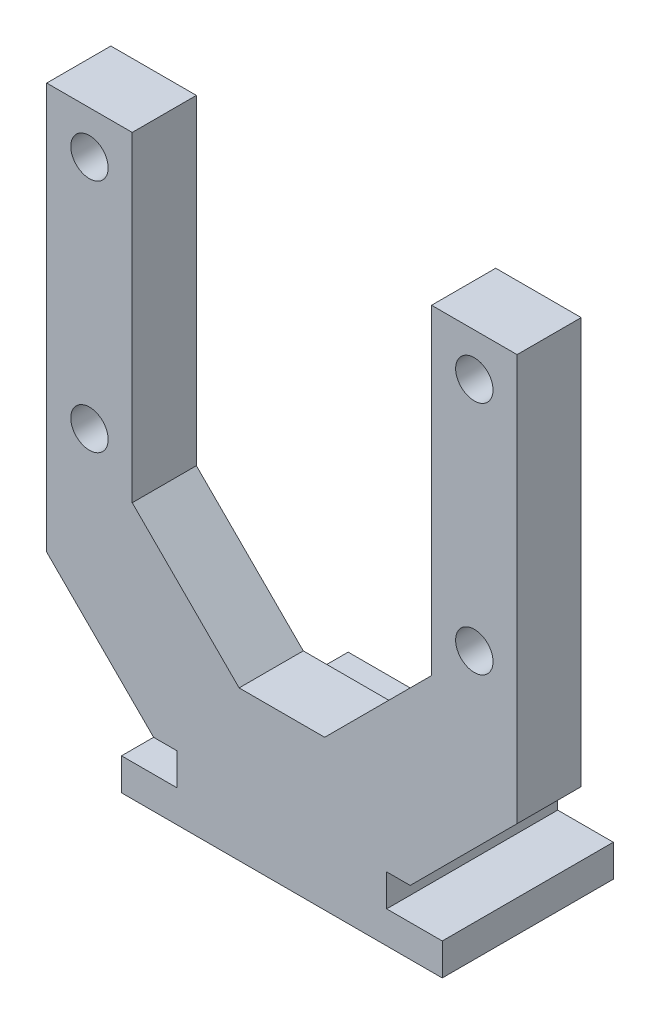
from build123d import *

# Parameters (mm, degrees)
SKETCH1_R           = 0.875
BOSS_EXTRUDE1_DEPTH = 3
CHAMFER1_SIZE       = 5
BOSS_EXTRUDE2_DEPTH = 5
SKETCH2_R           = 1.5
CUT_EXTRUDE1_DEPTH  = 27.870057685
CHAMFER2_SIZE       = 1


with BuildPart() as part:
    # Sketch1 → Boss-Extrude1 (new body)
    with BuildSketch(Plane.XY):
        Polygon((-7.5, 1.5), (-7.5, 0), (7.5, 0), (7.5, 1.5), (4.9, 1.5), (4.9, 3), (11, 3), (11, 27), (7, 27), (7, 7), (-7, 7), (-7, 27), (-11, 27), (-11, 3), (-4.9, 3), (-4.9, 1.5), align=None)
        with Locations((9, 25)):
            Circle(SKETCH1_R, mode=Mode.SUBTRACT)
        with Locations((-9, 14)):
            Circle(SKETCH1_R, mode=Mode.SUBTRACT)
        with Locations((-9, 25)):
            Circle(SKETCH1_R, mode=Mode.SUBTRACT)
        with Locations((9, 14)):
            Circle(SKETCH1_R, mode=Mode.SUBTRACT)
    extrude(amount=BOSS_EXTRUDE1_DEPTH)

    # Chamfer1
    chamfer1_edges = [part.edges().sort_by_distance(p)[0] for p in [
        (7, 7, 1.5),
        (-7, 7, 1.5),
        (-11, 3, 1.5),
        (11, 3, 1.5),
    ]]
    chamfer(chamfer1_edges, length=CHAMFER1_SIZE)

    # Sketch1_4 → Boss-Extrude2 (add)
    with BuildSketch(Plane.XY):
        Polygon((-7.5, 1.5), (-7.5, 0), (7.5, 0), (7.5, 1.5), (4.9, 1.5), (4.9, 3), (-4.9, 3), (-4.9, 1.5), align=None)
    extrude(amount=-BOSS_EXTRUDE2_DEPTH)

    # Sketch2 → Cut-Extrude1 (cut, through all)
    with BuildSketch(Plane(origin=(0, 3, 0), x_dir=(1, 0, 0), z_dir=(0, 1, 0))):
        with Locations((0, 3)):
            Circle(SKETCH2_R)
    extrude(amount=-CUT_EXTRUDE1_DEPTH, mode=Mode.SUBTRACT)

    # Chamfer2
    chamfer2_edges = [part.edges().sort_by_distance(p)[0] for p in [
        (0, 3, 0),
    ]]
    chamfer(chamfer2_edges, length=CHAMFER2_SIZE)


solid = part.part
